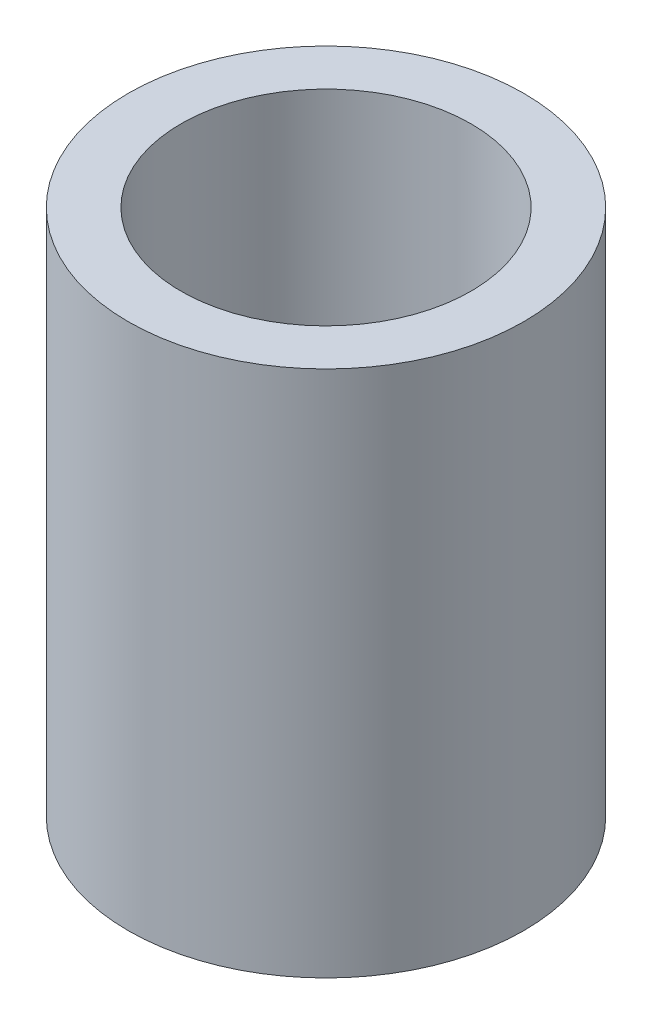
from build123d import *

# Parameters (mm, degrees)
SKETCH1_W = 0.4
SKETCH1_H = 4


with BuildPart() as part:
    # Sketch1 → Revolve1 (revolve)
    with BuildSketch(Plane.XY):
        with Locations((1.3, 2)):
            Rectangle(SKETCH1_W, SKETCH1_H)
    revolve(axis=Axis((0, 0, 0), (0, 1, 0)))


solid = part.part
